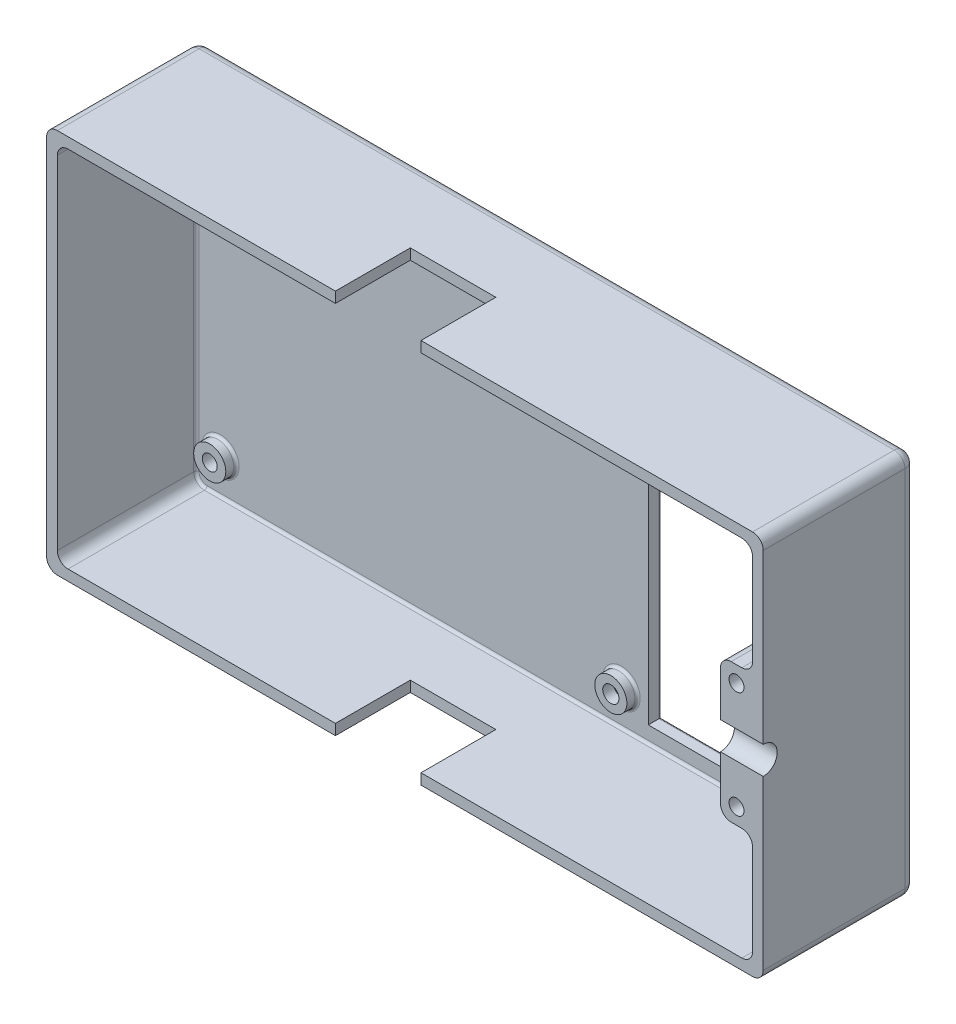
from build123d import *

# Parameters (mm, degrees)
SKETCH_1_W          = 134
SKETCH_1_H          = 72
SKETCH_1_R          = 1.4
SKETCH_1_W_2        = 37
SKETCH_1_H_2        = 62
EXTRUDE_1_DEPTH     = 2.5
SKETCH_2_W          = 134
SKETCH_2_H          = 72
SKETCH_2_R          = 1.4
EXTRUDE_2_DEPTH     = 26
SKETCH_3_R          = 2.6
CUT_EXTRUDE_1_DEPTH = 26
SKETCH_4_W          = 16
SKETCH_4_H          = 14
CUT_EXTRUDE_2_DEPTH = 26
SKETCH_5_R          = 3
SKETCH_5_R_2        = 1.4
SKETCH_5_R_3        = 1.517223762
SKETCH_5_R_4        = 3.1
EXTRUDE_4_DEPTH     = 2
FILLET_1_R          = 2
FILLET_2_R          = 2
FILLET_3_R          = 0.5
FILLET_4_R          = 2
FILLET_5_R          = 0.5
SKETCH_6_W          = 16
SKETCH_6_H          = 14
CUT_EXTRUDE_3_DEPTH = 2


with BuildPart() as part:
    # Эскиз1 → Бобышка-Вытянуть1 (new body)
    with BuildSketch(Plane.XY):
        with Locations((-4.814095612, -11.985488692)):
            Rectangle(SKETCH_1_W, SKETCH_1_H)
        with Locations((-65.314095612, 15.514511308)):
            Circle(SKETCH_1_R, mode=Mode.SUBTRACT)
        with Locations((9.685904388, 15.514511308)):
            Circle(SKETCH_1_R, mode=Mode.SUBTRACT)
        with Locations((9.685904388, -39.485488692)):
            Circle(SKETCH_1_R, mode=Mode.SUBTRACT)
        with Locations((-65.314095612, -39.485488692)):
            Circle(SKETCH_1_R, mode=Mode.SUBTRACT)
        with Locations((57.185904388, 15.514511308)):
            Circle(SKETCH_1_R, mode=Mode.SUBTRACT)
        with Locations((57.185904388, -39.485488692)):
            Circle(SKETCH_1_R, mode=Mode.SUBTRACT)
        with Locations((57.185904388, -1.985488692)):
            Circle(SKETCH_1_R, mode=Mode.SUBTRACT)
        with Locations((57.185904388, -21.985488692)):
            Circle(SKETCH_1_R, mode=Mode.SUBTRACT)
        with Locations((33.185904388, -11.985488692)):
            Rectangle(SKETCH_1_W_2, SKETCH_1_H_2, mode=Mode.SUBTRACT)
    extrude(amount=EXTRUDE_1_DEPTH)

    # Эскиз2 → Бобышка-Вытянуть2 (add)
    with BuildSketch(Plane.XY.offset(2.5)):
        with Locations((-4.814095612, -11.985488692)):
            Rectangle(SKETCH_2_W, SKETCH_2_H)
        with Locations((57.185904388, -1.985488692)):
            Circle(SKETCH_2_R, mode=Mode.SUBTRACT)
        with Locations((57.185904388, -21.985488692)):
            Circle(SKETCH_2_R, mode=Mode.SUBTRACT)
        Polygon((-69.814095612, 22.014511308), (60.185904388, 22.014511308), (60.185904388, 1.014511308), (54.185904388, 1.014511308), (54.185904388, -24.985488692), (60.185904388, -24.985488692), (60.185904388, -45.985488692), (-69.814095612, -45.985488692), align=None, mode=Mode.SUBTRACT)
    extrude(amount=EXTRUDE_2_DEPTH)

    # Эскиз3 → Вырез-Вытянуть1 (cut)
    with BuildSketch(Plane(origin=(62.185904388, 0, 0), x_dir=(0, 0, -1), z_dir=(1, 0, 0))):
        with Locations((-28.5, -11.985488692)):
            Circle(SKETCH_3_R)
    extrude(amount=-CUT_EXTRUDE_1_DEPTH, mode=Mode.SUBTRACT)

    # Эскиз4 → Вырез-Вытянуть2 (cut)
    with BuildSketch(Plane.XZ.offset(47.985488692)):
        with Locations((-9.814095612, 21.5)):
            Rectangle(SKETCH_4_W, SKETCH_4_H)
    extrude(amount=-CUT_EXTRUDE_2_DEPTH, mode=Mode.SUBTRACT)

    # Эскиз5 → Бобышка-Вытянуть4 (add)
    with BuildSketch(Plane.XY.offset(2.5)):
        with Locations((-65.314095612, 15.514511308)):
            Circle(SKETCH_5_R)
        with Locations((-65.314095612, 15.514511308)):
            Circle(SKETCH_5_R_2, mode=Mode.SUBTRACT)
        with Locations((9.685904388, 15.514511308)):
            Circle(SKETCH_5_R)
        with Locations((9.685904388, 15.514511308)):
            Circle(SKETCH_5_R_2, mode=Mode.SUBTRACT)
        with Locations((9.685904388, -39.485488692)):
            Circle(SKETCH_5_R)
        with Locations((9.685904388, -39.485488692)):
            Circle(SKETCH_5_R_3, mode=Mode.SUBTRACT)
        with Locations((-65.314095612, -39.485488692)):
            Circle(SKETCH_5_R)
        with Locations((-65.314095612, -39.485488692)):
            Circle(SKETCH_5_R_2, mode=Mode.SUBTRACT)
        with Locations((57.185904388, -39.485488692)):
            Circle(SKETCH_5_R_4)
        with Locations((57.185904388, -39.485488692)):
            Circle(SKETCH_5_R_2, mode=Mode.SUBTRACT)
        with Locations((57.185904388, 15.514511308)):
            Circle(SKETCH_5_R_4)
        with Locations((57.185904388, 15.514511308)):
            Circle(SKETCH_5_R_2, mode=Mode.SUBTRACT)
    extrude(amount=EXTRUDE_4_DEPTH)

    # Скругление1
    fillet_1_edges = [part.edges().sort_by_distance(p)[0] for p in [
        (-71.814095612, 24.014511308, 14.25),
        (62.185904388, 24.014511308, 14.25),
        (62.185904388, -47.985488692, 14.25),
        (-71.814095612, -47.985488692, 14.25),
    ]]
    fillet(fillet_1_edges, radius=FILLET_1_R)

    # Скругление2
    fillet_2_edges = [part.edges().sort_by_distance(p)[0] for p in [
        (-69.814095612, -45.985488692, 15.5),
        (60.185904388, -45.985488692, 15.5),
        (60.185904388, -24.985488692, 15.5),
        (54.185904388, -24.985488692, 15.5),
        (54.185904388, 1.014511308, 15.5),
        (60.185904388, 1.014511308, 15.5),
        (60.185904388, 22.014511308, 15.5),
        (-69.814095612, 22.014511308, 15.5),
    ]]
    fillet(fillet_2_edges, radius=FILLET_2_R)

    # Скругление3
    fillet_3_edges = [part.edges().sort_by_distance(p)[0] for p in [
        (-68.314095612, 15.514511308, 2.5),
        (6.685904388, 15.514511308, 2.5),
        (-68.314095612, -39.485488692, 2.5),
        (6.685904388, -39.485488692, 2.5),
        (60.185904388, -32.844976209, 2.5),
        (54.085904388, -39.485488692, 2.5),
        (60.185904388, 18.155023791, 2.5),
        (54.085904388, 15.514511308, 2.5),
        (-69.814095612, -11.985488692, 2.5),
        (-4.814095612, 22.014511308, 2.5),
        (-4.814095612, -45.985488692, 2.5),
        (60.185904388, -42.126001176, 2.5),
        (57.185904388, -24.985488692, 2.5),
        (54.185904388, -11.985488692, 2.5),
        (57.185904388, 1.014511308, 2.5),
        (60.185904388, 8.873998824, 2.5),
        (59.60011795, -45.399702255, 2.5),
        (59.60011795, 1.600297745, 2.5),
        (59.60011795, 21.42872487, 2.5),
        (59.60011795, -25.57127513, 2.5),
        (-69.228309174, 21.42872487, 2.5),
        (-69.228309174, -45.399702255, 2.5),
        (54.771690826, -24.399702255, 2.5),
        (54.771690826, 0.42872487, 2.5),
    ]]
    fillet(fillet_3_edges, radius=FILLET_3_R)

    # Скругление4
    fillet_4_edges = [part.edges().sort_by_distance(p)[0] for p in [
        (-4.814095612, 24.014511308, 0),
        (-71.814095612, -11.985488692, 0),
        (62.185904388, -11.985488692, 0),
        (-4.814095612, -47.985488692, 0),
        (-71.228309174, 23.42872487, 0),
        (-71.228309174, -47.399702255, 0),
        (61.60011795, -47.399702255, 0),
        (61.60011795, 23.42872487, 0),
    ]]
    fillet(fillet_4_edges, radius=FILLET_4_R)

    # Скругление5
    fillet_5_edges = [part.edges().sort_by_distance(p)[0] for p in [
        (14.685904388, -11.985488692, 0),
        (33.185904388, -42.985488692, 0),
        (51.685904388, -11.985488692, 0),
        (33.185904388, 19.014511308, 0),
        (-66.714095612, 15.514511308, 0),
        (8.285904388, 15.514511308, 0),
        (8.285904388, -39.485488692, 0),
        (-66.714095612, -39.485488692, 0),
        (55.785904388, 15.514511308, 0),
        (55.785904388, -39.485488692, 0),
        (55.785904388, -1.985488692, 0),
        (55.785904388, -21.985488692, 0),
    ]]
    fillet(fillet_5_edges, radius=FILLET_5_R)

    # Эскиз6 → Вырез-Вытянуть3 (cut)
    with BuildSketch(Plane(origin=(0, 24.014511308, 0), x_dir=(1, 0, 0), z_dir=(0, 1, 0))):
        with Locations((-9.814095612, -21.5)):
            Rectangle(SKETCH_6_W, SKETCH_6_H)
    extrude(amount=-CUT_EXTRUDE_3_DEPTH, mode=Mode.SUBTRACT)


solid = part.part
